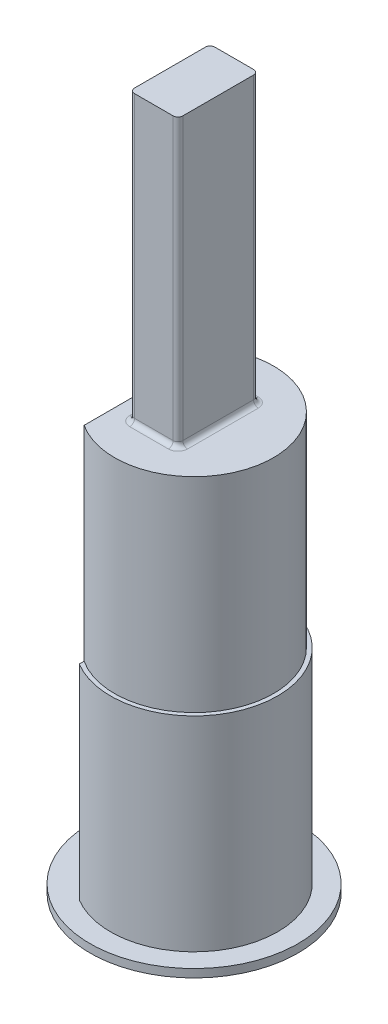
from build123d import *

# Parameters (mm, degrees)
BOSS_EXTRUDE1_DEPTH = 25.4
BOSS_EXTRUDE2_DEPTH = 17.78
FILLET1_R           = 0.3
SKETCH3_R           = 6.46557
BOSS_EXTRUDE3_DEPTH = 0.508
SKETCH4_OUTSIDE_W   = 24.404
SKETCH4_OUTSIDE_H   = 24.404
SKETCH4_OUTSIDE_R   = 4.94157
CUT_EXTRUDE1_DEPTH  = 12.7


with BuildPart() as part:
    # Sketch1 → Boss-Extrude1 (new body)
    with BuildSketch(Plane(origin=(0, 0, 0), x_dir=(1, 0, 0), z_dir=(0, 1, 0))):
        with BuildLine():
            Line((-2.68996703, 4.445), (-2.68996703, -4.445))
            ThreePointArc((-2.68996703, -4.445), (5.19557, 0), (-2.68996703, 4.445))
        make_face()
    extrude(amount=BOSS_EXTRUDE1_DEPTH)

    # Sketch2 → Boss-Extrude2 (add)
    with BuildSketch(Plane(origin=(0, 25.4, 0), x_dir=(1, 0, 0), z_dir=(0, 1, 0))):
        with BuildLine():
            Line((-1.2, -2.5), (1.2, -2.5))
            ThreePointArc((1.2, -2.5), (1.412132034, -2.412132034), (1.5, -2.2))
            Line((1.5, -2.2), (1.5, 2.2))
            ThreePointArc((1.5, 2.2), (1.412132034, 2.412132034), (1.2, 2.5))
            Line((1.2, 2.5), (-1.2, 2.5))
            ThreePointArc((-1.2, 2.5), (-1.412132034, 2.412132034), (-1.5, 2.2))
            Line((-1.5, 2.2), (-1.5, -2.2))
            ThreePointArc((-1.5, -2.2), (-1.412132034, -2.412132034), (-1.2, -2.5))
        make_face()
    extrude(amount=BOSS_EXTRUDE2_DEPTH)

    # Fillet1
    fillet1_edges = [part.edges().sort_by_distance(p)[0] for p in [
        (-1.412132034, 25.4, 2.412132034),
        (0, 25.4, 2.5),
        (1.412132034, 25.4, 2.412132034),
        (1.5, 25.4, 0),
        (1.412132034, 25.4, -2.412132034),
        (0, 25.4, -2.5),
        (-1.412132034, 25.4, -2.412132034),
        (-1.5, 25.4, 0),
    ]]
    fillet(fillet1_edges, radius=FILLET1_R)

    # Sketch3 → Boss-Extrude3 (add)
    with BuildSketch(Plane.XZ):
        Circle(SKETCH3_R)
    extrude(amount=BOSS_EXTRUDE3_DEPTH)

    # Sketch4 outside → Cut-Extrude1 (cut)
    with BuildSketch(Plane(origin=(0, 25.4, 0), x_dir=(1, 0, 0), z_dir=(0, 1, 0))):
        Rectangle(SKETCH4_OUTSIDE_W, SKETCH4_OUTSIDE_H)
        Circle(SKETCH4_OUTSIDE_R, mode=Mode.SUBTRACT)
    extrude(amount=-CUT_EXTRUDE1_DEPTH, mode=Mode.SUBTRACT)


solid = part.part
